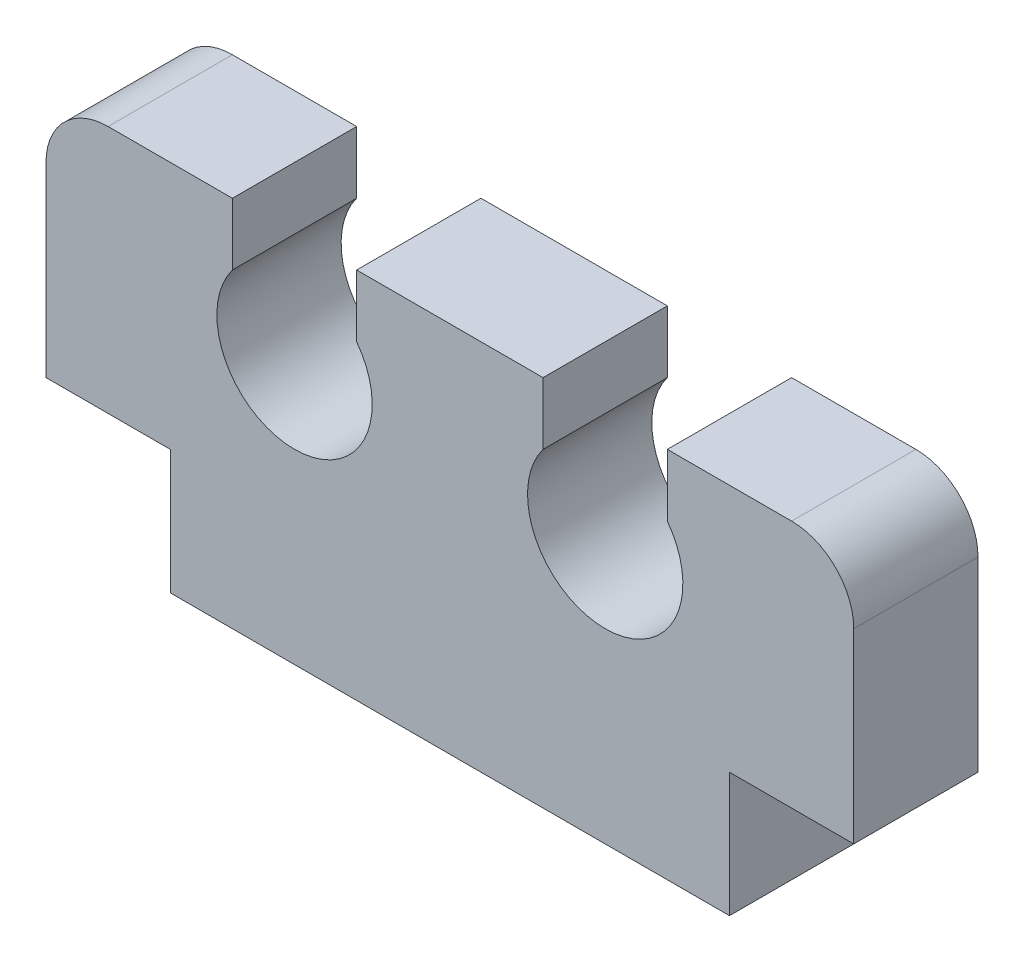
from build123d import *

# Parameters (mm, degrees)
BOSS_EXTRUDE1_DEPTH = 2


with BuildPart() as part:
    # Model → Boss-Extrude1 (new body)
    with BuildSketch(Plane.XY):
        with BuildLine():
            Line((11, 2), (11, 5))
            ThreePointArc((11, 5), (10.707106781, 5.707106781), (10, 6))
            Line((10, 6), (8, 6))
            Line((8, 6), (8, 5))
            ThreePointArc((8, 5), (7, 3), (6, 5))
            Line((6, 5), (6, 6))
            Line((6, 6), (3, 6))
            Line((3, 6), (3, 5))
            ThreePointArc((3, 5), (2, 3), (1, 5))
            Line((1, 5), (1, 6))
            Line((1, 6), (-1, 6))
            ThreePointArc((-1, 6), (-1.707106781, 5.707106781), (-2, 5))
            Line((-2, 5), (-2, 2))
            Line((-2, 2), (0, 2))
            Line((0, 2), (0, 0))
            Line((0, 0), (9, 0))
            Line((9, 0), (9, 2))
            Line((9, 2), (11, 2))
        make_face()
    extrude(amount=BOSS_EXTRUDE1_DEPTH)


solid = part.part
